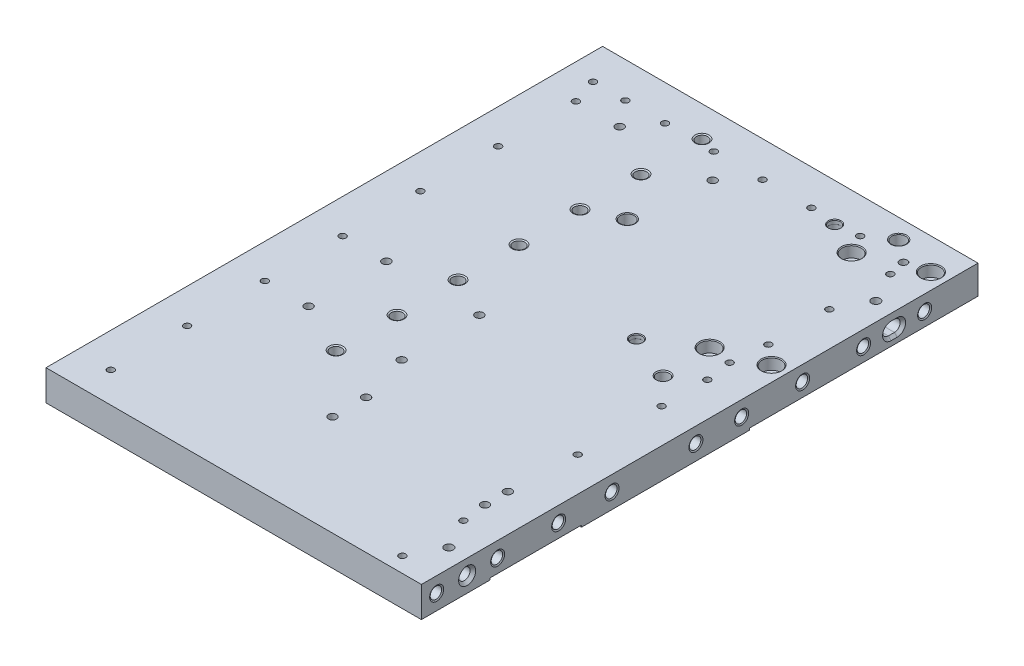
from build123d import *

# Parameters (mm, degrees)
SKETCH1_W                                     = 312.674
SKETCH1_H                                     = 463.55
EXTRUDE1_DEPTH                                = 12.7
F_3_8_16_TAPPED_HOLE1_AT_2_COUNT              = 2
F_3_8_16_TAPPED_HOLE1_AT_2_PITCH              = 64.77
F_3_8_16_TAPPED_HOLE1_AT_3_COUNT              = 2
F_3_8_16_TAPPED_HOLE1_AT_3_PITCH              = 129.54
F_3_8_16_TAPPED_HOLE1_AT_4_COUNT              = 2
F_3_8_16_TAPPED_HOLE1_AT_4_PITCH              = 194.31
F_3_8_16_TAPPED_HOLE1_AT_5_COUNT              = 2
F_3_8_16_TAPPED_HOLE1_AT_5_PITCH              = 259.08
F_3_8_16_TAPPED_HOLE1_AT_6_COUNT              = 2
F_3_8_16_TAPPED_HOLE1_AT_6_PITCH              = 323.85
F_3_8_16_TAPPED_HOLE1_AT_7_COUNT              = 2
F_3_8_16_TAPPED_HOLE1_AT_7_PITCH              = 387.35
F_7_32_0_21875_DIAMETER_HOLE1_D               = 5.55625
F_3_8_16_TAPPED_HOLE2_AT_2_COUNT              = 2
F_3_8_16_TAPPED_HOLE2_AT_2_PITCH              = 355.6
F_3_8_16_TAPPED_HOLE2_AT_3_COUNT              = 2
F_3_8_16_TAPPED_HOLE2_AT_3_PITCH              = 304.8
F_3_8_16_TAPPED_HOLE2_AT_4_COUNT              = 2
F_3_8_16_TAPPED_HOLE2_AT_4_PITCH              = 254
F_3_8_16_TAPPED_HOLE2_AT_5_COUNT              = 2
F_3_8_16_TAPPED_HOLE2_AT_5_PITCH              = 209.55
F_3_8_16_TAPPED_HOLE2_AT_6_COUNT              = 2
F_3_8_16_TAPPED_HOLE2_AT_6_PITCH              = 139.7
F_3_8_16_TAPPED_HOLE2_AT_7_COUNT              = 2
F_3_8_16_TAPPED_HOLE2_AT_7_PITCH              = 101.6
F_3_8_16_TAPPED_HOLE2_AT_8_COUNT              = 2
F_3_8_16_TAPPED_HOLE2_AT_8_PITCH              = 50.8
F_3_8_16_TAPPED_HOLE2_AT_9_COUNT              = 2
F_3_8_16_TAPPED_HOLE2_AT_9_PITCH              = 50.8
F_7_32_0_21875_DIAMETER_HOLE2_D               = 5.55625
TAPPED_HOLE_FOR_3_8_16_HELICOIL1_AT_2_COUNT   = 2
TAPPED_HOLE_FOR_3_8_16_HELICOIL1_AT_2_PITCH   = 121.92
TAPPED_HOLE_FOR_3_8_16_HELICOIL1_AT_3_COUNT   = 2
TAPPED_HOLE_FOR_3_8_16_HELICOIL1_AT_3_PITCH   = 81.28
TAPPED_HOLE_FOR_3_8_16_HELICOIL1_AT_4_COUNT   = 2
TAPPED_HOLE_FOR_3_8_16_HELICOIL1_AT_4_PITCH   = 40.64
TAPPED_HOLE_FOR_3_8_16_HELICOIL1_AT_5_COUNT   = 2
TAPPED_HOLE_FOR_3_8_16_HELICOIL1_AT_5_PITCH   = 40.64
TAPPED_HOLE_FOR_3_8_16_HELICOIL1_AT_6_COUNT   = 2
TAPPED_HOLE_FOR_3_8_16_HELICOIL1_AT_6_PITCH   = 73.66
TAPPED_HOLE_FOR_3_8_16_HELICOIL1_AT_7_COUNT   = 2
TAPPED_HOLE_FOR_3_8_16_HELICOIL1_AT_7_PITCH   = 162.56
F_7_32_0_21875_DIAMETER_HOLE3_D               = 5.55625
EXTRUDE2_DEPTH                                = 19.05
F_3_8_0_375_DIAMETER_HOLE1_D                  = 9.54278
F_3_8_0_375_DIAMETER_HOLE1_DEPTH              = 19.05
F_3_8_0_375_DIAMETER_HOLE1_CSINK_D            = 14.224
F_3_8_0_375_DIAMETER_HOLE1_CSINK_ANGLE        = 90
F_3_8_0_375_DIAMETER_HOLE1_TIP                = 2.866940349
CHAMFER1_SIZE                                 = 2.286
CBORE_FOR_3_8_SOCKET_HEAD_CAP_SCREW1_AT_COUNT = 2
CBORE_FOR_3_8_SOCKET_HEAD_CAP_SCREW1_AT_PITCH = 127.98052832
CBORE_FOR_3_8_SOCKET_HEAD_CAP_SCREW1_2_COUNT  = 2
CBORE_FOR_3_8_SOCKET_HEAD_CAP_SCREW1_2_PITCH  = 123.825
CBORE_FOR_3_8_SOCKET_HEAD_CAP_SCREW1_3_COUNT  = 2
CBORE_FOR_3_8_SOCKET_HEAD_CAP_SCREW1_3_PITCH  = 50.704660535
SKETCH20_W                                    = 101.6
SKETCH20_H                                    = 190.5
CUT_EXTRUDE1_DEPTH                            = 1.524
FILLET1_R                                     = 12.7
CUT_EXTRUDE2_DEPTH                            = 9.652
CHAMFER2_SIZE                                 = 1.524
F_1_4_DOWEL_HOLE_D                            = 6.36778
F_1_4_DOWEL_HOLE_CSINK_D                      = 9.652
F_1_4_DOWEL_HOLE_CSINK_ANGLE                  = 90
F_7_32_0_21875_DIAMETER_HOLE5_D               = 5.55625
F_7_32_0_21875_DIAMETER_HOLE5_DEPTH           = 14.224
CUT_EXTRUDE3_DEPTH                            = 1.524
TAPPED_HOLE_FOR_1_4_20_HELICOIL2_AT_2_COUNT   = 2
TAPPED_HOLE_FOR_1_4_20_HELICOIL2_AT_2_PITCH   = 194.31
TAPPED_HOLE_FOR_1_4_20_HELICOIL2_AT_3_COUNT   = 2
TAPPED_HOLE_FOR_1_4_20_HELICOIL2_AT_3_PITCH   = 259.08
TAPPED_HOLE_FOR_1_4_20_HELICOIL2_AT_4_COUNT   = 2
TAPPED_HOLE_FOR_1_4_20_HELICOIL2_AT_4_PITCH   = 270.414584111
TAPPED_HOLE_FOR_1_4_20_HELICOIL2_AT_5_COUNT   = 2
TAPPED_HOLE_FOR_1_4_20_HELICOIL2_AT_5_PITCH   = 209.184074442
TAPPED_HOLE_FOR_1_4_20_HELICOIL2_AT_6_COUNT   = 2
TAPPED_HOLE_FOR_1_4_20_HELICOIL2_AT_6_PITCH   = 77.47
TAPPED_HOLE_FOR_1_4_20_HELICOIL1_AT_2_COUNT   = 2
TAPPED_HOLE_FOR_1_4_20_HELICOIL1_AT_2_PITCH   = 19.05
TAPPED_HOLE_FOR_1_4_20_HELICOIL1_AT_3_COUNT   = 2
TAPPED_HOLE_FOR_1_4_20_HELICOIL1_AT_3_PITCH   = 127.310769772
TAPPED_HOLE_FOR_1_4_20_HELICOIL1_AT_4_COUNT   = 2
TAPPED_HOLE_FOR_1_4_20_HELICOIL1_AT_4_PITCH   = 128.420802443
L4C_HOLES_TAPPED_HOLE_FOR_3_8_16_HEL_2_COUNT  = 2
L4C_HOLES_TAPPED_HOLE_FOR_3_8_16_HEL_2_PITCH  = 161.209398747
HOLES_FOR_PINS_3_8_CLEARANCE_HOLE1_AT_2_COUNT = 2
HOLES_FOR_PINS_3_8_CLEARANCE_HOLE1_AT_2_PITCH = 165.1
VENT_HOLES_FOR_PINS_7_32_0_21875_DIAME_D      = 7.14375
F_3_8_16_TAPPED_HOLE3_D                       = 9.525
F_3_8_16_TAPPED_HOLE3_CSINK_D                 = 11.684
F_3_8_16_TAPPED_HOLE3_CSINK_ANGLE             = 120
F_9_32_0_28125_DIAMETER_HOLE1_D               = 7.14375
F_9_32_0_28125_DIAMETER_HOLE2_D               = 6.35
F_9_32_0_28125_DIAMETER_HOLE2_DEPTH           = 25.4
F_9_32_0_28125_DIAMETER_HOLE2_TIP             = 1.833087105


with BuildPart() as part:
    # Sketch1 → Extrude1 (new body, symmetric)
    with BuildSketch(Plane(origin=(0, 0, 0), x_dir=(1, 0, 0), z_dir=(0, 1, 0))):
        Rectangle(SKETCH1_W, SKETCH1_H)
    extrude(amount=EXTRUDE1_DEPTH, both=True)

    # Sketch4 → 3/8-16 Tapped Hole1 (revolve, cut)
    with BuildSketch(Plane(origin=(-156.337, 0, -180.975), x_dir=(0, 0, 1), z_dir=(0, 1, 0))):
        Polygon((0, 0), (0, 34.134665582), (3.96875, 31.75), (3.96875, 25.4), (4.7625, 25.4), (4.7625, 0.623249616), (5.842, 0), align=None)
    f_3_8_16_tapped_hole1 = revolve(axis=Axis((-162.687, 0, -180.975), (1, 0, 0)), mode=Mode.SUBTRACT)

    # 3/8-16 Tapped Hole1 at 2: 3/8-16 Tapped Hole1 ×2
    with Locations(*[(0, 0, i * F_3_8_16_TAPPED_HOLE1_AT_2_PITCH) for i in range(1, F_3_8_16_TAPPED_HOLE1_AT_2_COUNT)]):
        add(f_3_8_16_tapped_hole1, mode=Mode.SUBTRACT)

    # 3/8-16 Tapped Hole1 at 3: 3/8-16 Tapped Hole1 ×2
    with Locations(*[(0, 0, i * F_3_8_16_TAPPED_HOLE1_AT_3_PITCH) for i in range(1, F_3_8_16_TAPPED_HOLE1_AT_3_COUNT)]):
        add(f_3_8_16_tapped_hole1, mode=Mode.SUBTRACT)

    # 3/8-16 Tapped Hole1 at 4: 3/8-16 Tapped Hole1 ×2
    with Locations(*[(0, 0, i * F_3_8_16_TAPPED_HOLE1_AT_4_PITCH) for i in range(1, F_3_8_16_TAPPED_HOLE1_AT_4_COUNT)]):
        add(f_3_8_16_tapped_hole1, mode=Mode.SUBTRACT)

    # 3/8-16 Tapped Hole1 at 5: 3/8-16 Tapped Hole1 ×2
    with Locations(*[(0, 0, i * F_3_8_16_TAPPED_HOLE1_AT_5_PITCH) for i in range(1, F_3_8_16_TAPPED_HOLE1_AT_5_COUNT)]):
        add(f_3_8_16_tapped_hole1, mode=Mode.SUBTRACT)

    # 3/8-16 Tapped Hole1 at 6: 3/8-16 Tapped Hole1 ×2
    with Locations(*[(0, 0, i * F_3_8_16_TAPPED_HOLE1_AT_6_PITCH) for i in range(1, F_3_8_16_TAPPED_HOLE1_AT_6_COUNT)]):
        add(f_3_8_16_tapped_hole1, mode=Mode.SUBTRACT)

    # 3/8-16 Tapped Hole1 at 7: 3/8-16 Tapped Hole1 ×2
    with Locations(*[(0, 0, i * F_3_8_16_TAPPED_HOLE1_AT_7_PITCH) for i in range(1, F_3_8_16_TAPPED_HOLE1_AT_7_COUNT)]):
        add(f_3_8_16_tapped_hole1, mode=Mode.SUBTRACT)

    # 7/32 (0.21875) Diameter Hole1 (through all)
    with Locations(Plane.XZ.offset(12.7)):
        with Locations((-127.762, 13.335), (-127.762, 206.375), (-127.762, 142.875), (-127.762, -180.975), (-127.762, -116.205), (-127.762, -51.435), (-127.762, 78.105)):
            Hole(F_7_32_0_21875_DIAMETER_HOLE1_D / 2)

    # Sketch7 → 3/8-16 Tapped Hole2 (revolve, cut)
    with BuildSketch(Plane(origin=(156.337, 0, -136.525), x_dir=(0, 0, -1), z_dir=(0, 1, 0))):
        Polygon((0, 0), (0, 34.134665582), (3.96875, 31.75), (3.96875, 25.4), (4.7625, 25.4), (4.7625, 0.623249616), (5.842, 0), align=None)
    f_3_8_16_tapped_hole2 = revolve(axis=Axis((162.687, 0, -136.525), (-1, 0, 0)), mode=Mode.SUBTRACT)

    # 3/8-16 Tapped Hole2 at 2: 3/8-16 Tapped Hole2 ×2
    with Locations(*[(0, 0, i * F_3_8_16_TAPPED_HOLE2_AT_2_PITCH) for i in range(1, F_3_8_16_TAPPED_HOLE2_AT_2_COUNT)]):
        add(f_3_8_16_tapped_hole2, mode=Mode.SUBTRACT)

    # 3/8-16 Tapped Hole2 at 3: 3/8-16 Tapped Hole2 ×2
    with Locations(*[(0, 0, i * F_3_8_16_TAPPED_HOLE2_AT_3_PITCH) for i in range(1, F_3_8_16_TAPPED_HOLE2_AT_3_COUNT)]):
        add(f_3_8_16_tapped_hole2, mode=Mode.SUBTRACT)

    # 3/8-16 Tapped Hole2 at 4: 3/8-16 Tapped Hole2 ×2
    with Locations(*[(0, 0, i * F_3_8_16_TAPPED_HOLE2_AT_4_PITCH) for i in range(1, F_3_8_16_TAPPED_HOLE2_AT_4_COUNT)]):
        add(f_3_8_16_tapped_hole2, mode=Mode.SUBTRACT)

    # 3/8-16 Tapped Hole2 at 5: 3/8-16 Tapped Hole2 ×2
    with Locations(*[(0, 0, i * F_3_8_16_TAPPED_HOLE2_AT_5_PITCH) for i in range(1, F_3_8_16_TAPPED_HOLE2_AT_5_COUNT)]):
        add(f_3_8_16_tapped_hole2, mode=Mode.SUBTRACT)

    # 3/8-16 Tapped Hole2 at 6: 3/8-16 Tapped Hole2 ×2
    with Locations(*[(0, 0, i * F_3_8_16_TAPPED_HOLE2_AT_6_PITCH) for i in range(1, F_3_8_16_TAPPED_HOLE2_AT_6_COUNT)]):
        add(f_3_8_16_tapped_hole2, mode=Mode.SUBTRACT)

    # 3/8-16 Tapped Hole2 at 7: 3/8-16 Tapped Hole2 ×2
    with Locations(*[(0, 0, i * F_3_8_16_TAPPED_HOLE2_AT_7_PITCH) for i in range(1, F_3_8_16_TAPPED_HOLE2_AT_7_COUNT)]):
        add(f_3_8_16_tapped_hole2, mode=Mode.SUBTRACT)

    # 3/8-16 Tapped Hole2 at 8: 3/8-16 Tapped Hole2 ×2
    with Locations(*[(0, 0, i * F_3_8_16_TAPPED_HOLE2_AT_8_PITCH) for i in range(1, F_3_8_16_TAPPED_HOLE2_AT_8_COUNT)]):
        add(f_3_8_16_tapped_hole2, mode=Mode.SUBTRACT)

    # 3/8-16 Tapped Hole2 at 9: 3/8-16 Tapped Hole2 ×2
    with Locations(*[(0, 0, -i * F_3_8_16_TAPPED_HOLE2_AT_9_PITCH) for i in range(1, F_3_8_16_TAPPED_HOLE2_AT_9_COUNT)]):
        add(f_3_8_16_tapped_hole2, mode=Mode.SUBTRACT)

    # 7/32 (0.21875) Diameter Hole2 (through all)
    with Locations(Plane.XZ.offset(12.7)):
        with Locations((127.762, -34.925), (127.762, -187.325), (127.762, -136.525), (127.762, -85.725), (127.762, 3.175), (127.762, 73.025), (127.762, 168.275), (127.762, 219.075)):
            Hole(F_7_32_0_21875_DIAMETER_HOLE2_D / 2)

    # Sketch11 → Tapped Hole for 3/8-16 Helicoil1 (revolve, cut)
    with BuildSketch(Plane(origin=(-34.163, 0, -231.775), x_dir=(0, 1, 0), z_dir=(1, 0, 0))):
        Polygon((0, 0), (0, 36.049479155), (5.0419, 33.02), (5.0419, 22.86), (5.84454, 22.86), (5.84454, 0.438474435), (6.604, 0), align=None)
    tapped_hole_for_3_8_16_helicoil1 = revolve(axis=Axis((-34.163, 0, -238.125), (0, 0, 1)), mode=Mode.SUBTRACT)

    # Tapped Hole for 3/8-16 Helicoil1 at 2: Tapped Hole for 3/8-16 Helicoil1 ×2
    with Locations(*[(i * TAPPED_HOLE_FOR_3_8_16_HELICOIL1_AT_2_PITCH, 0, 0) for i in range(1, TAPPED_HOLE_FOR_3_8_16_HELICOIL1_AT_2_COUNT)]):
        add(tapped_hole_for_3_8_16_helicoil1, mode=Mode.SUBTRACT)

    # Tapped Hole for 3/8-16 Helicoil1 at 3: Tapped Hole for 3/8-16 Helicoil1 ×2
    with Locations(*[(i * TAPPED_HOLE_FOR_3_8_16_HELICOIL1_AT_3_PITCH, 0, 0) for i in range(1, TAPPED_HOLE_FOR_3_8_16_HELICOIL1_AT_3_COUNT)]):
        add(tapped_hole_for_3_8_16_helicoil1, mode=Mode.SUBTRACT)

    # Tapped Hole for 3/8-16 Helicoil1 at 4: Tapped Hole for 3/8-16 Helicoil1 ×2
    with Locations(*[(i * TAPPED_HOLE_FOR_3_8_16_HELICOIL1_AT_4_PITCH, 0, 0) for i in range(1, TAPPED_HOLE_FOR_3_8_16_HELICOIL1_AT_4_COUNT)]):
        add(tapped_hole_for_3_8_16_helicoil1, mode=Mode.SUBTRACT)

    # Tapped Hole for 3/8-16 Helicoil1 at 5: Tapped Hole for 3/8-16 Helicoil1 ×2
    with Locations(*[(-i * TAPPED_HOLE_FOR_3_8_16_HELICOIL1_AT_5_PITCH, 0, 0) for i in range(1, TAPPED_HOLE_FOR_3_8_16_HELICOIL1_AT_5_COUNT)]):
        add(tapped_hole_for_3_8_16_helicoil1, mode=Mode.SUBTRACT)

    # Tapped Hole for 3/8-16 Helicoil1 at 6: Tapped Hole for 3/8-16 Helicoil1 ×2
    with Locations(*[(-i * TAPPED_HOLE_FOR_3_8_16_HELICOIL1_AT_6_PITCH, 0, 0) for i in range(1, TAPPED_HOLE_FOR_3_8_16_HELICOIL1_AT_6_COUNT)]):
        add(tapped_hole_for_3_8_16_helicoil1, mode=Mode.SUBTRACT)

    # Tapped Hole for 3/8-16 Helicoil1 at 7: Tapped Hole for 3/8-16 Helicoil1 ×2
    with Locations(*[(i * TAPPED_HOLE_FOR_3_8_16_HELICOIL1_AT_7_PITCH, 0, 0) for i in range(1, TAPPED_HOLE_FOR_3_8_16_HELICOIL1_AT_7_COUNT)]):
        add(tapped_hole_for_3_8_16_helicoil1, mode=Mode.SUBTRACT)

    # 7/32 (0.21875) Diameter Hole3 (through all)
    with Locations(Plane.XZ.offset(12.7)):
        with Locations((6.477, -202.2094), (-107.823, -202.2094), (-74.803, -202.2094), (-34.163, -202.2094), (47.117, -202.2094), (87.757, -202.2094), (-134.747, -202.2094)):
            Hole(F_7_32_0_21875_DIAMETER_HOLE3_D / 2)

    # Sketch15 → Extrude2 (cut)
    with BuildSketch(Plane(origin=(156.337, 0, 0), x_dir=(0, 0, -1), z_dir=(1, 0, 0))):
        with BuildLine():
            Line((159.385, 4.77139), (164.465, 4.77139))
            ThreePointArc((164.465, 4.77139), (169.23639, 0), (164.465, -4.77139))
            Line((164.465, -4.77139), (159.385, -4.77139))
            ThreePointArc((159.385, -4.77139), (154.61361, 0), (159.385, 4.77139))
        make_face()
    extrude(amount=-EXTRUDE2_DEPTH, mode=Mode.SUBTRACT)

    # 3/8 (0.375) Diameter Hole1
    with Locations(Plane(origin=(156.337, 0, 0), x_dir=(0, 0, -1), z_dir=(1, 0, 0))):
        with Locations((-193.675, 0)):
            CounterSinkHole(F_3_8_0_375_DIAMETER_HOLE1_D / 2, F_3_8_0_375_DIAMETER_HOLE1_CSINK_D / 2, depth=F_3_8_0_375_DIAMETER_HOLE1_DEPTH, counter_sink_angle=F_3_8_0_375_DIAMETER_HOLE1_CSINK_ANGLE)
            with Locations((0, 0, -(F_3_8_0_375_DIAMETER_HOLE1_DEPTH + F_3_8_0_375_DIAMETER_HOLE1_TIP / 2))):  # 118° drill point
                Cone(0, F_3_8_0_375_DIAMETER_HOLE1_D / 2, F_3_8_0_375_DIAMETER_HOLE1_TIP, mode=Mode.SUBTRACT)

    # Chamfer1
    chamfer1_edges = [part.edges().sort_by_distance(p)[0] for p in [
        (156.337, 0, -154.61361),
        (156.337, -4.77139, -161.925),
        (156.337, 0, -169.23639),
        (156.337, 4.77139, -161.925),
    ]]
    chamfer(chamfer1_edges, length=CHAMFER1_SIZE)

    # Sketch18 → CBORE for 3/8 Socket Head Cap Screw1 (revolve, cut)
    with BuildSketch(Plane(origin=(96.139, 12.7, -186.69), x_dir=(0, 0, 1), z_dir=(1, 0, 0))):
        Polygon((0, 0), (0, 25.4), (4.9022, 25.4), (4.9022, 9.525), (7.9375, 9.525), (7.9375, 0.635), (8.5725, 0), align=None)
    cbore_for_3_8_socket_head_cap_screw1 = revolve(axis=Axis((96.139, 19.05, -186.69), (0, -1, 0)), mode=Mode.SUBTRACT)

    # CBORE for 3/8 Socket Head Cap Screw1 at: CBORE for 3/8 Socket Head Cap Screw1 ×2
    with Locations(*[Vector(0.073433046, 0, 0.997300149) * (i * CBORE_FOR_3_8_SOCKET_HEAD_CAP_SCREW1_AT_PITCH) for i in range(1, CBORE_FOR_3_8_SOCKET_HEAD_CAP_SCREW1_AT_COUNT)]):
        add(cbore_for_3_8_socket_head_cap_screw1, mode=Mode.SUBTRACT)

    # CBORE for 3_8 Socket Head Cap Screw1 2: CBORE for 3/8 Socket Head Cap Screw1 ×2
    with Locations(*[Vector(0.384615385, 0, 0.923076923) * (i * CBORE_FOR_3_8_SOCKET_HEAD_CAP_SCREW1_2_PITCH) for i in range(1, CBORE_FOR_3_8_SOCKET_HEAD_CAP_SCREW1_2_COUNT)]):
        add(cbore_for_3_8_socket_head_cap_screw1, mode=Mode.SUBTRACT)

    # CBORE for 3_8 Socket Head Cap Screw1 3: CBORE for 3/8 Socket Head Cap Screw1 ×2
    with Locations(*[Vector(0.926739268, 0, -0.375705109) * (i * CBORE_FOR_3_8_SOCKET_HEAD_CAP_SCREW1_3_PITCH) for i in range(1, CBORE_FOR_3_8_SOCKET_HEAD_CAP_SCREW1_3_COUNT)]):
        add(cbore_for_3_8_socket_head_cap_screw1, mode=Mode.SUBTRACT)

    # Sketch20 → Cut-Extrude1 (cut)
    with BuildSketch(Plane.XZ.offset(12.7)):
        with Locations((105.537, -136.525)):
            Rectangle(SKETCH20_W, SKETCH20_H)
    extrude(amount=-CUT_EXTRUDE1_DEPTH, mode=Mode.SUBTRACT)

    # Fillet1
    fillet1_edges = [part.edges().sort_by_distance(p)[0] for p in [
        (54.737, -11.938, -41.275),
    ]]
    fillet(fillet1_edges, radius=FILLET1_R)

    # Sketch21 → Cut-Extrude2 (cut)
    with BuildSketch(Plane.XZ.offset(11.176)):
        with BuildLine():
            Line((121.53011, -58.166), (121.53011, -54.864))
            ThreePointArc((121.53011, -54.864), (124.714, -51.68011), (127.89789, -54.864))
            Line((127.89789, -54.864), (127.89789, -58.166))
            ThreePointArc((127.89789, -58.166), (124.714, -61.34989), (121.53011, -58.166))
        make_face()
    extrude(amount=-CUT_EXTRUDE2_DEPTH, mode=Mode.SUBTRACT)

    # Chamfer2
    chamfer2_edges = [part.edges().sort_by_distance(p)[0] for p in [
        (124.714, -11.176, -61.34989),
        (127.89789, -11.176, -56.515),
        (124.714, -11.176, -51.68011),
        (121.53011, -11.176, -56.515),
    ]]
    chamfer(chamfer2_edges, length=CHAMFER2_SIZE)

    # 1/4 DOWEL HOLE (through all)
    with Locations(Plane.XZ.offset(11.176)):
        with Locations((124.714, -201.295)):
            CounterSinkHole(F_1_4_DOWEL_HOLE_D / 2, F_1_4_DOWEL_HOLE_CSINK_D / 2, counter_sink_angle=F_1_4_DOWEL_HOLE_CSINK_ANGLE)

    # 7/32 (0.21875) Diameter Hole5
    with Locations(Plane(origin=(0, 12.7, 0), x_dir=(-1, 0, 0), z_dir=(0, 1, 0))):
        with Locations((-124.714, -56.515)):
            Hole(F_7_32_0_21875_DIAMETER_HOLE5_D / 2, depth=F_7_32_0_21875_DIAMETER_HOLE5_DEPTH)

    # Sketch24 → Cut-Extrude3 (cut)
    with BuildSketch(Plane.XZ.offset(12.7)):
        with BuildLine():
            Line((-15.113, 98.425), (156.337, 98.425))
            Line((156.337, 98.425), (156.337, 174.625))
            Line((156.337, 174.625), (-15.113, 174.625))
            ThreePointArc((-15.113, 174.625), (-24.093256121, 170.905256121), (-27.813, 161.925))
            Line((-27.813, 161.925), (-27.813, 111.125))
            ThreePointArc((-27.813, 111.125), (-24.093256121, 102.144743879), (-15.113, 98.425))
        make_face()
    extrude(amount=-CUT_EXTRUDE3_DEPTH, mode=Mode.SUBTRACT)

    # Sketch50 → Tapped Hole for 1/4-20 Helicoil2 (revolve, cut)
    with BuildSketch(Plane(origin=(-91.313, -12.7, -180.975), x_dir=(0, 0, -1), z_dir=(1, 0, 0))):
        Polygon((0, 0), (0, 25.4), (3.3782, 25.4), (3.3782, 15.748), (4.04749, 15.748), (4.04749, 0.366617421), (4.68249, 0), align=None)
    tapped_hole_for_1_4_20_helicoil2 = revolve(axis=Axis((-91.313, -19.05, -180.975), (0, 1, 0)), mode=Mode.SUBTRACT)

    # Tapped Hole for 1/4-20 Helicoil2 at 2: Tapped Hole for 1/4-20 Helicoil2 ×2
    with Locations(*[(0, 0, i * TAPPED_HOLE_FOR_1_4_20_HELICOIL2_AT_2_PITCH) for i in range(1, TAPPED_HOLE_FOR_1_4_20_HELICOIL2_AT_2_COUNT)]):
        add(tapped_hole_for_1_4_20_helicoil2, mode=Mode.SUBTRACT)

    # Tapped Hole for 1/4-20 Helicoil2 at 3: Tapped Hole for 1/4-20 Helicoil2 ×2
    with Locations(*[(0, 0, i * TAPPED_HOLE_FOR_1_4_20_HELICOIL2_AT_3_PITCH) for i in range(1, TAPPED_HOLE_FOR_1_4_20_HELICOIL2_AT_3_COUNT)]):
        add(tapped_hole_for_1_4_20_helicoil2, mode=Mode.SUBTRACT)

    # Tapped Hole for 1/4-20 Helicoil2 at 4: Tapped Hole for 1/4-20 Helicoil2 ×2
    with Locations(*[Vector(0.286486028, 0, 0.95808442) * (i * TAPPED_HOLE_FOR_1_4_20_HELICOIL2_AT_4_PITCH) for i in range(1, TAPPED_HOLE_FOR_1_4_20_HELICOIL2_AT_4_COUNT)]):
        add(tapped_hole_for_1_4_20_helicoil2, mode=Mode.SUBTRACT)

    # Tapped Hole for 1/4-20 Helicoil2 at 5: Tapped Hole for 1/4-20 Helicoil2 ×2
    with Locations(*[Vector(0.37034368, 0, 0.928894805) * (i * TAPPED_HOLE_FOR_1_4_20_HELICOIL2_AT_5_PITCH) for i in range(1, TAPPED_HOLE_FOR_1_4_20_HELICOIL2_AT_5_COUNT)]):
        add(tapped_hole_for_1_4_20_helicoil2, mode=Mode.SUBTRACT)

    # Tapped Hole for 1/4-20 Helicoil2 at 6: Tapped Hole for 1/4-20 Helicoil2 ×2
    with Locations(*[(i * TAPPED_HOLE_FOR_1_4_20_HELICOIL2_AT_6_PITCH, 0, 0) for i in range(1, TAPPED_HOLE_FOR_1_4_20_HELICOIL2_AT_6_COUNT)]):
        add(tapped_hole_for_1_4_20_helicoil2, mode=Mode.SUBTRACT)

    # Sketch26 → Tapped Hole for 1/4-20 Helicoil1 (revolve, cut)
    with BuildSketch(Plane(origin=(125.349, -11.176, 128.778), x_dir=(0, 0, -1), z_dir=(1, 0, 0))):
        Polygon((0, 0), (0, 23.876), (3.3782, 23.876), (3.3782, 15.748), (4.04749, 15.748), (4.04749, 0.30282599), (4.572, 0), align=None)
    tapped_hole_for_1_4_20_helicoil1 = revolve(axis=Axis((125.349, -17.526, 128.778), (0, 1, 0)), mode=Mode.SUBTRACT)

    # Tapped Hole for 1/4-20 Helicoil1 at 2: Tapped Hole for 1/4-20 Helicoil1 ×2
    with Locations(*[(0, 0, i * TAPPED_HOLE_FOR_1_4_20_HELICOIL1_AT_2_PITCH) for i in range(1, TAPPED_HOLE_FOR_1_4_20_HELICOIL1_AT_2_COUNT)]):
        add(tapped_hole_for_1_4_20_helicoil1, mode=Mode.SUBTRACT)

    # Tapped Hole for 1/4-20 Helicoil1 at 3: Tapped Hole for 1/4-20 Helicoil1 ×2
    with Locations(*[Vector(-0.997558967, 0, -0.069829128) * (i * TAPPED_HOLE_FOR_1_4_20_HELICOIL1_AT_3_PITCH) for i in range(1, TAPPED_HOLE_FOR_1_4_20_HELICOIL1_AT_3_COUNT)]):
        add(tapped_hole_for_1_4_20_helicoil1, mode=Mode.SUBTRACT)

    # Tapped Hole for 1/4-20 Helicoil1 at 4: Tapped Hole for 1/4-20 Helicoil1 ×2
    with Locations(*[Vector(-0.988936353, 0, 0.148340453) * (i * TAPPED_HOLE_FOR_1_4_20_HELICOIL1_AT_4_PITCH) for i in range(1, TAPPED_HOLE_FOR_1_4_20_HELICOIL1_AT_4_COUNT)]):
        add(tapped_hole_for_1_4_20_helicoil1, mode=Mode.SUBTRACT)

    # Sketch28 → L4C Holes Tapped Hole for 3/8-16 Helicoil2 (revolve, cut)
    with BuildSketch(Plane(origin=(-21.463, 12.7, -117.475), x_dir=(0, 0, 1), z_dir=(1, 0, 0))):
        Polygon((0, 0), (0, 25.4), (5.0419, 25.4), (5.0419, 22.86), (5.84454, 22.86), (5.84454, 0.438474435), (6.604, 0), align=None)
    l4c_holes_tapped_hole_for_3_8_16_helicoi = revolve(axis=Axis((-21.463, 19.05, -117.475), (0, -1, 0)), mode=Mode.SUBTRACT)

    # L4C Holes Tapped Hole for 3_8-16 Hel 2: L4C Holes Tapped Hole for 3/8-16 Helicoil2 ×2
    with Locations(*[Vector(0.79335334, 0, -0.608761429) * (i * L4C_HOLES_TAPPED_HOLE_FOR_3_8_16_HEL_2_PITCH) for i in range(1, L4C_HOLES_TAPPED_HOLE_FOR_3_8_16_HEL_2_COUNT)]):
        add(l4c_holes_tapped_hole_for_3_8_16_helicoi, mode=Mode.SUBTRACT)

    # Sketch30 → Holes for Pins 3/8 Clearance Hole1 (revolve, cut)
    with BuildSketch(Plane(origin=(68.707, 12.7, -34.925), x_dir=(0, 0, 1), z_dir=(1, 0, 0))):
        Polygon((0, 0), (0, 20.0025), (4.7625, 15.24), (4.7625, 3.302), (4.7879, 3.302), (4.7879, 0.5461), (5.334, 0), align=None)
    holes_for_pins_3_8_clearance_hole1 = revolve(axis=Axis((68.707, 19.05, -34.925), (0, -1, 0)), mode=Mode.SUBTRACT)

    # Holes for Pins 3/8 Clearance Hole1 at 2: Holes for Pins 3/8 Clearance Hole1 ×2
    with Locations(*[(0, 0, -i * HOLES_FOR_PINS_3_8_CLEARANCE_HOLE1_AT_2_PITCH) for i in range(1, HOLES_FOR_PINS_3_8_CLEARANCE_HOLE1_AT_2_COUNT)]):
        add(holes_for_pins_3_8_clearance_hole1, mode=Mode.SUBTRACT)

    # Vent Holes for Pins 7/32 (0.21875) Diameter Hole4 (through all)
    with Locations(Plane(origin=(-225.044, 12.7, 349.25), x_dir=(-1, 0, 0), z_dir=(0, 1, 0))):
        with Locations((-293.751, -384.175), (-293.751, -549.275)):
            Hole(VENT_HOLES_FOR_PINS_7_32_0_21875_DIAME_D / 2)

    # 3/8-16 Tapped Hole3 (through all)
    with Locations(Plane(origin=(0, 12.7, 0), x_dir=(-1, 0, 0), z_dir=(0, 1, 0))):
        with Locations((48.133, -206.375), (48.133, -155.575), (48.133, -104.775), (48.133, -53.975), (48.133, -3.175), (48.133, 47.625), (48.133, 98.425)):
            CounterSinkHole(F_3_8_16_TAPPED_HOLE3_D / 2, F_3_8_16_TAPPED_HOLE3_CSINK_D / 2, counter_sink_angle=F_3_8_16_TAPPED_HOLE3_CSINK_ANGLE)

    # 9/32 (0.28125) Diameter Hole1 (through all)
    with Locations(Plane.XZ.offset(12.7)):
        with Locations((141.097, 193.675), (141.097, -161.925)):
            Hole(F_9_32_0_28125_DIAMETER_HOLE1_D / 2)

    # Sketch38 → CBORE for 3/8 Socket Head Cap Screw2 (revolve, cut)
    with BuildSketch(Plane(origin=(106.433014982, -12.7, -19.336936049), x_dir=(0, 0, -1), z_dir=(1, 0, 0))):
        Polygon((0, 0), (0, 25.4), (5.842, 25.4), (5.15874, 24.613999282), (5.15874, 12.7), (8.7376, 12.7), (8.7376, 0), align=None)
    revolve(axis=Axis((106.433014982, -19.05, -19.336936049), (0, 1, 0)), mode=Mode.SUBTRACT)

    # Sketch40 → CBORE for 3/8 Socket Head Cap Screw3 (revolve, cut)
    with BuildSketch(Plane(origin=(-156.337, 0, -202.214802169), x_dir=(0, 0, 1), z_dir=(0, 1, 0))):
        Polygon((0, 0), (0, 18.101598698), (4.7625, 15.24), (4.7625, 3.302), (4.7879, 3.302), (4.7879, 0.5461), (5.334, 0), align=None)
    revolve(axis=Axis((-162.687, 0, -202.214802169), (1, 0, 0)), mode=Mode.SUBTRACT)

    # 9/32 (0.28125) Diameter Hole2
    with Locations(Plane.ZY.offset(156.337)):
        with Locations((-202.214802169, 0)):
            Hole(F_9_32_0_28125_DIAMETER_HOLE2_D / 2, depth=F_9_32_0_28125_DIAMETER_HOLE2_DEPTH)
            with Locations((0, 0, -(F_9_32_0_28125_DIAMETER_HOLE2_DEPTH + F_9_32_0_28125_DIAMETER_HOLE2_TIP / 2))):  # 120° drill point
                Cone(0, F_9_32_0_28125_DIAMETER_HOLE2_D / 2, F_9_32_0_28125_DIAMETER_HOLE2_TIP, mode=Mode.SUBTRACT)


solid = part.part
